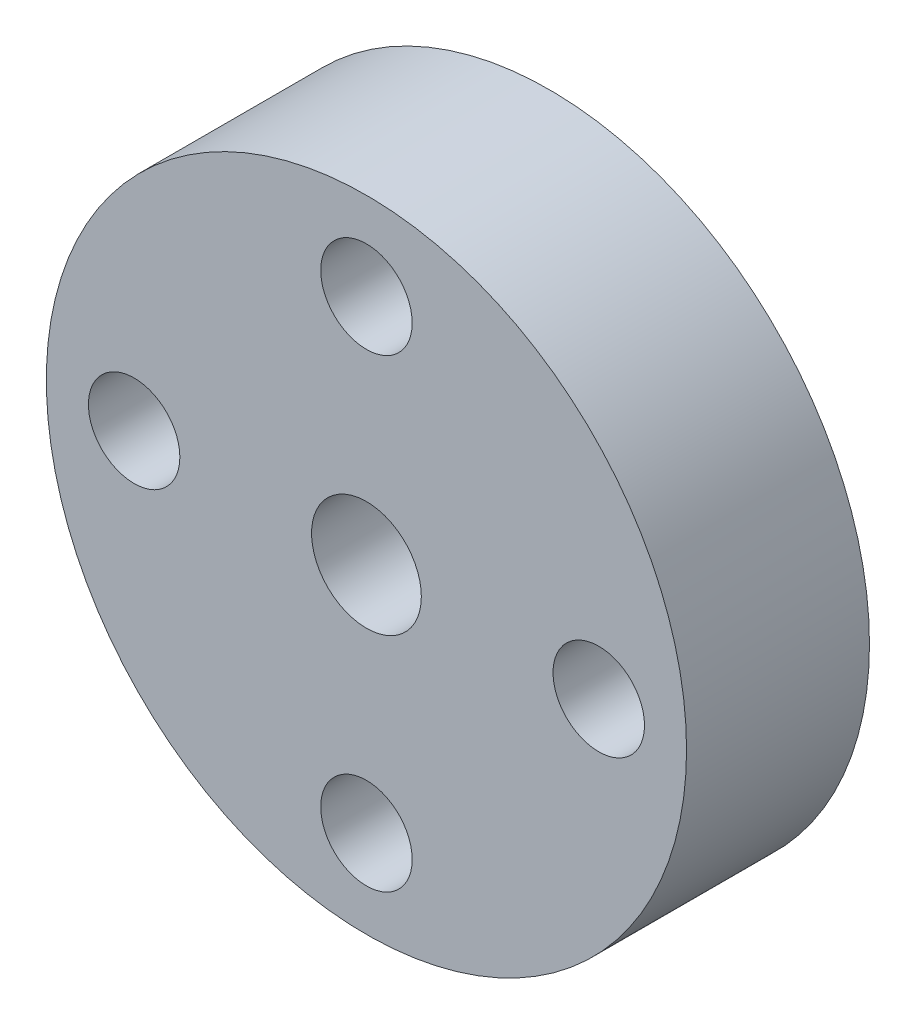
from build123d import *

# Parameters (mm, degrees)
SKETCH_1_R             = 8.75
EXTRUDE_1_DEPTH        = 5
HOLE_WIZARD_M3_1_D     = 2.5
HOLE_WIZARD_M3_1_DEPTH = 5
SKETCH_4_R             = 1.5
CUT_EXTRUDE_1_DEPTH    = 6


with BuildPart() as part:
    # 스케치1 → 보스-돌출1 (new body)
    with BuildSketch(Plane.XY):
        Circle(SKETCH_1_R)
    extrude(amount=EXTRUDE_1_DEPTH)

    # M3 나사 구멍1
    with Locations(Plane.XY.offset(5)):
        with Locations((0, 6.35), (6.35, 0), (0, -6.35), (-6.35, 0)):
            Hole(HOLE_WIZARD_M3_1_D / 2, depth=HOLE_WIZARD_M3_1_DEPTH)

    # 스케치4 → 컷-돌출1 (cut, through all)
    with BuildSketch(Plane.XY.offset(5)):
        Circle(SKETCH_4_R)
    extrude(amount=-CUT_EXTRUDE_1_DEPTH, mode=Mode.SUBTRACT)


solid = part.part
